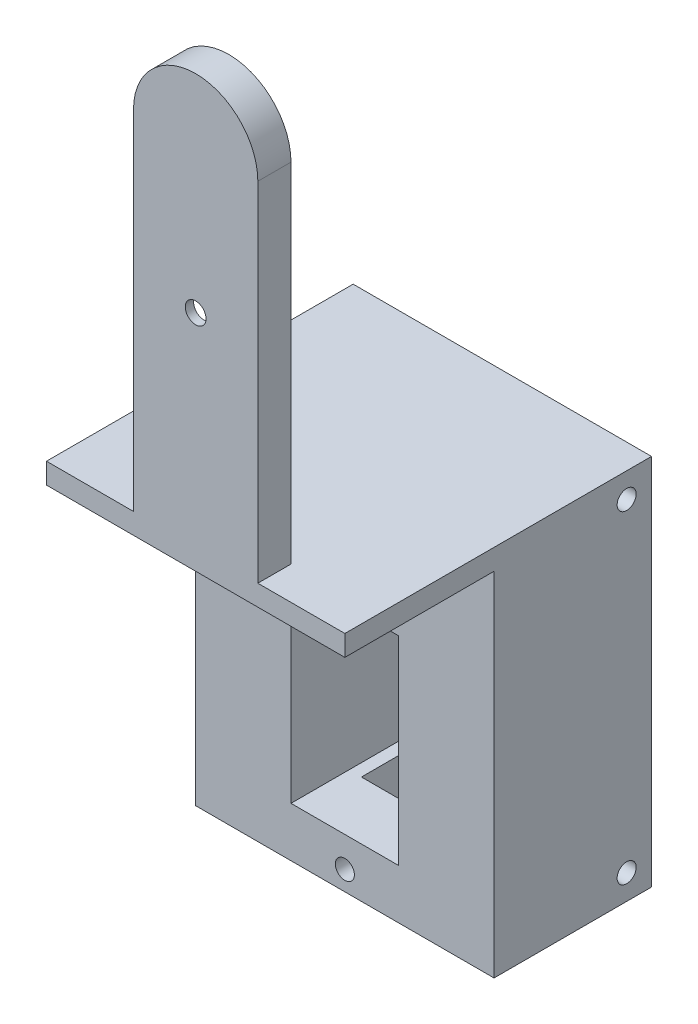
from build123d import *

# Parameters (mm, degrees)
EXTRUDE_1_DEPTH     = 4
CUT_EXTRUDE_1_DEPTH = 3
SKETCH_5_R          = 1.25
CUT_EXTRUDE_2_DEPTH = 12.4
SKETCH_13_W         = 36
SKETCH_13_H         = 45
EXTRUDE_2_DEPTH     = 37
SKETCH_14_W         = 13
SKETCH_14_H         = 24
CUT_EXTRUDE_3_DEPTH = 35
SKETCH_15_R         = 1.15
CUT_EXTRUDE_4_DEPTH = 31
SKETCH_16_W         = 10
SKETCH_16_H         = 8
CUT_EXTRUDE_5_DEPTH = 8
SKETCH_17_W         = 36
SKETCH_17_H         = 42.5
CUT_EXTRUDE_6_DEPTH = 18
SKETCH_23_R         = 1.15
CUT_EXTRUDE_7_DEPTH = 5
SKETCH_24_R         = 1.15
CUT_EXTRUDE_8_DEPTH = 5


with BuildPart() as part:
    # 草圖1 → 填料-伸長1 (new body)
    with BuildSketch(Plane.XY):
        with BuildLine():
            Line((7.5, 10), (7.5, 52))
            ThreePointArc((7.5, 52), (0, 59.5), (-7.5, 52))
            Line((-7.5, 52), (-7.5, 10))
            Line((-7.5, 10), (7.5, 10))
        make_face()
    extrude(amount=EXTRUDE_1_DEPTH)

    # 草圖3 → 除料-伸長1 (cut)
    with BuildSketch(Plane.XY):
        with BuildLine():
            ThreePointArc((-2.132795501, 52), (0, 54.132795501), (2.132795501, 52))
            Line((2.132795501, 52), (5, 34.5))
            Line((5, 34.5), (2.114741289, 16.658021353))
            ThreePointArc((2.114741289, 16.658021353), (-0.171540182, 14.864665347), (-2.142213835, 17))
            Line((-2.142213835, 17), (-5, 34.5))
            Line((-5, 34.5), (-2.132795501, 52))
        make_face()
    extrude(amount=CUT_EXTRUDE_1_DEPTH, mode=Mode.SUBTRACT)

    # 草圖5 → 除料-伸長2 (cut)
    with BuildSketch(Plane.XY):
        with Locations((0, 34.5)):
            Circle(SKETCH_5_R)
    extrude(amount=CUT_EXTRUDE_2_DEPTH, mode=Mode.SUBTRACT)

    # 草圖13 → 填料-伸長2 (add)
    with BuildSketch(Plane.XY.offset(4)):
        with Locations((0, -12.5)):
            Rectangle(SKETCH_13_W, SKETCH_13_H)
    extrude(amount=-EXTRUDE_2_DEPTH)

    # 草圖14 → 除料-伸長3 (cut)
    with BuildSketch(Plane(origin=(0, 0, 4), x_dir=(-1, 0, 0), z_dir=(0, 0, -1))):
        with Locations((0, -17)):
            Rectangle(SKETCH_14_W, SKETCH_14_H)
    extrude(amount=CUT_EXTRUDE_3_DEPTH, mode=Mode.SUBTRACT)

    # 草圖15 → 除料-伸長4 (cut)
    with BuildSketch(Plane.XY.offset(4)):
        with Locations((0, -1.85)):
            Circle(SKETCH_15_R)
        with Locations((0, -32.65)):
            Circle(SKETCH_15_R)
    extrude(amount=-CUT_EXTRUDE_4_DEPTH, mode=Mode.SUBTRACT)

    # 草圖16 → 除料-伸長5 (cut)
    with BuildSketch(Plane(origin=(0, -35, 0), x_dir=(-1, 0, 0), z_dir=(0, -1, 0))):
        with Locations((0, 25)):
            Rectangle(SKETCH_16_W, SKETCH_16_H)
    extrude(amount=-CUT_EXTRUDE_5_DEPTH, mode=Mode.SUBTRACT)

    # 草圖17 → 除料-伸長6 (cut)
    with BuildSketch(Plane.XY.offset(4)):
        with Locations((0, -13.75)):
            Rectangle(SKETCH_17_W, SKETCH_17_H)
    extrude(amount=-CUT_EXTRUDE_6_DEPTH, mode=Mode.SUBTRACT)

    # 草圖23 → 除料-伸長7 (cut)
    with BuildSketch(Plane.ZY.offset(18)):
        with Locations((-30, 7)):
            Circle(SKETCH_23_R)
        with Locations((-30, -32)):
            Circle(SKETCH_23_R)
    extrude(amount=-CUT_EXTRUDE_7_DEPTH, mode=Mode.SUBTRACT)

    # 草圖24 → 除料-伸長8 (cut)
    with BuildSketch(Plane(origin=(18, 0, 0), x_dir=(0, 0, -1), z_dir=(1, 0, 0))):
        with Locations((30, 7)):
            Circle(SKETCH_24_R)
        with Locations((30, -32)):
            Circle(SKETCH_24_R)
    extrude(amount=-CUT_EXTRUDE_8_DEPTH, mode=Mode.SUBTRACT)


solid = part.part
